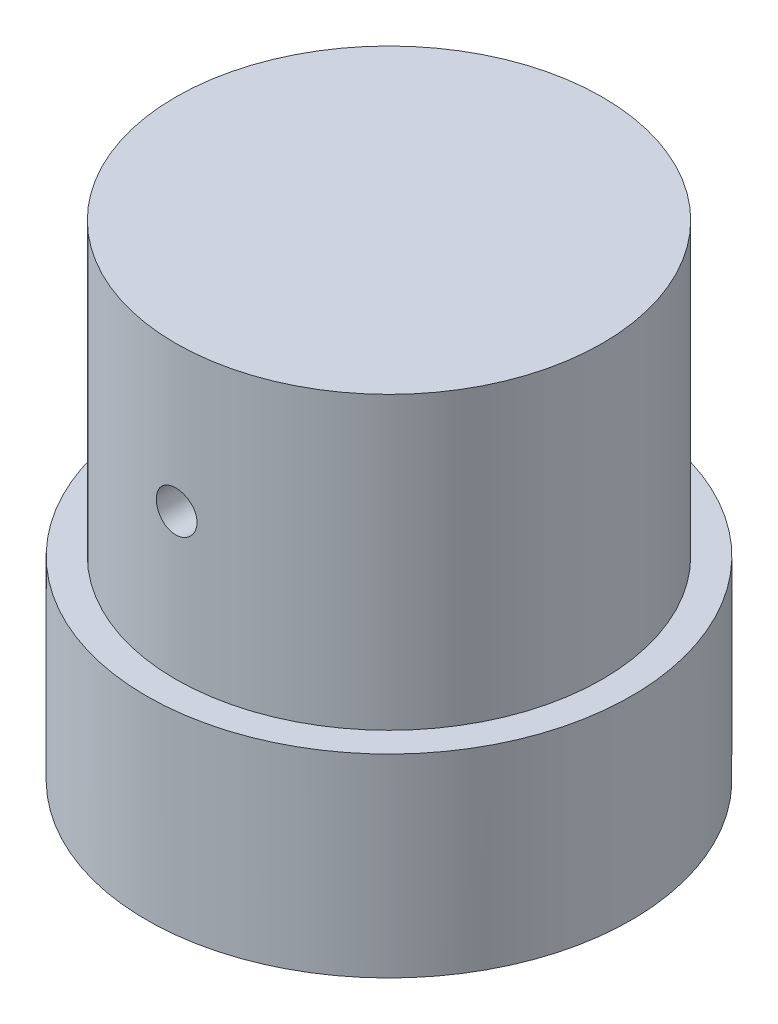
from build123d import *

# Parameters (mm, degrees)
ESBO_O1_R                = 22
RESSALTO_EXTRUS_O1_DEPTH = 30
ESBO_O2_W                = 51.6
ESBO_O2_H                = 51.6
RESSALTO_EXTRUS_O2_DEPTH = 20
CORTE_EXTRUS_O4_REACH    = 52
ESBO_O17_W               = 51.6
ESBO_O17_H               = 51.6
ESBO_O17_R               = 25
ESBO_O18_R               = 2.5
CORTE_EXTRUS_O5_DEPTH    = 15


with BuildPart() as part:
    # Esboço1 → Ressalto-extrusão1 (new body)
    with BuildSketch(Plane(origin=(0, 0, 0), x_dir=(1, 0, 0), z_dir=(0, 1, 0))):
        Circle(ESBO_O1_R)
    extrude(amount=RESSALTO_EXTRUS_O1_DEPTH)

    # Esboço2 → Ressalto-extrusão2 (add)
    with BuildSketch(Plane.XZ):
        Rectangle(ESBO_O2_W, ESBO_O2_H)
    extrude(amount=RESSALTO_EXTRUS_O2_DEPTH)

    # Esboço13 → Broca de rosquear para tarraxa de M52 (revolve, cut)
    with BuildSketch(Plane(origin=(0, 15, 25.8), x_dir=(0, -1, 0), z_dir=(1, 0, 0))):
        Polygon((0, 0), (0, 16.2618073), (2.1, 15), (2.1, 0), align=None)
    broca_de_rosquear_para_tarraxa_de_m52 = revolve(axis=Axis((0, 15, 32.15), (0, 0, -1)), mode=Mode.SUBTRACT)

    # Espelhar1: Broca de rosquear para tarraxa de M52 across plane
    add(broca_de_rosquear_para_tarraxa_de_m52.mirror(Plane.XY), mode=Mode.SUBTRACT)

    # Esboço17 → Corte-extrusão4 (cut, up to next)
    with BuildSketch(Plane.XZ.offset(20), mode=Mode.PRIVATE) as corte_extrus_o4_sk1:
        Rectangle(ESBO_O17_W, ESBO_O17_H)
        Circle(ESBO_O17_R, mode=Mode.SUBTRACT)
    corte_extrus_o4_tool1 = extrude(corte_extrus_o4_sk1.sketch, amount=-CORTE_EXTRUS_O4_REACH, mode=Mode.PRIVATE) & part.part
    add(corte_extrus_o4_tool1.solids().sort_by_distance((25.070266, -20, 0))[0], mode=Mode.SUBTRACT)

    # Esboço18 → Corte-extrusão5 (cut)
    with BuildSketch(Plane.XZ.offset(20)):
        with Locations((8.838834765, 8.838834765)):
            Circle(ESBO_O18_R)
        with Locations((-8.838834765, 8.838834765)):
            Circle(ESBO_O18_R)
        with Locations((8.838834765, -8.838834765)):
            Circle(ESBO_O18_R)
        with Locations((-8.838834765, -8.838834765)):
            Circle(ESBO_O18_R)
    extrude(amount=-CORTE_EXTRUS_O5_DEPTH, mode=Mode.SUBTRACT)


solid = part.part
